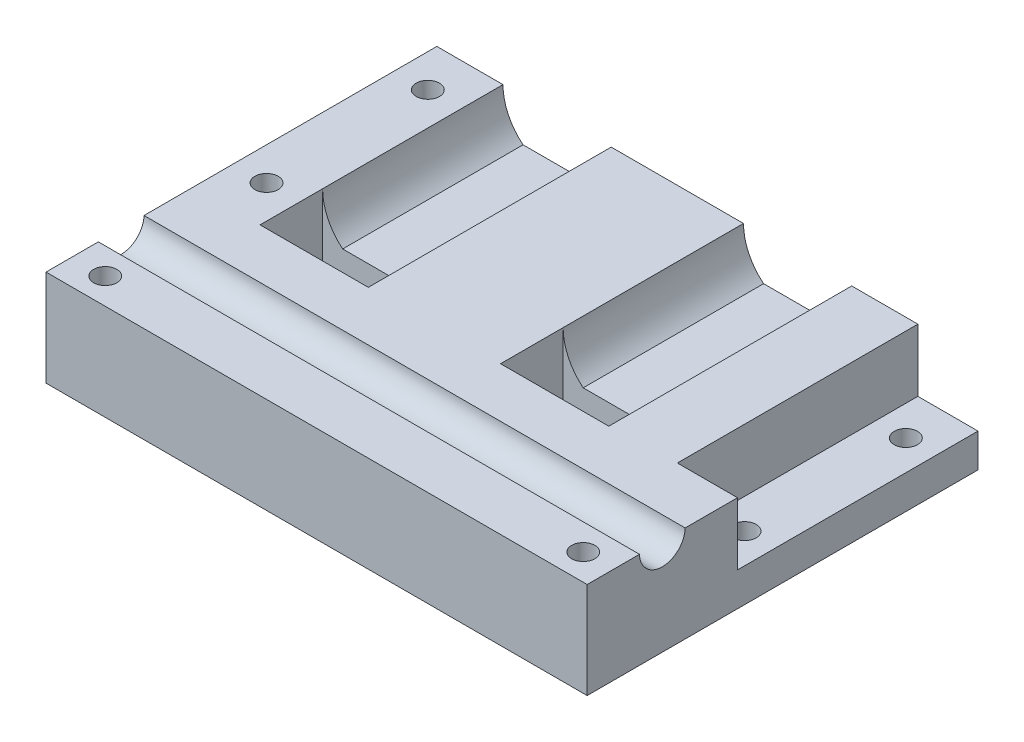
from build123d import *

# Parameters (mm, degrees)
BOSS_EXTRUDE1_DEPTH  = 38.1
SKETCH7_W            = 101.6
SKETCH7_H            = 20.32
BOSS_EXTRUDE2_DEPTH  = 44.45
BOSS_EXTRUDE8_DEPTH  = 12.7
SKETCH8_W            = 22.86
SKETCH8_H            = 13.208
CUT_EXTRUDE1_DEPTH   = 20.32
SKETCH9_R            = 4.826
CUT_EXTRUDE2_DEPTH   = 114.3
LPATTERN1_COUNT      = 3
LPATTERN1_PITCH      = 34.067332164
LPATTERN1_COUNT_DIR2 = 2
LPATTERN1_PITCH_DIR2 = 100.965


with BuildPart() as part:
    # Sketch1 → Boss-Extrude1 (new body)
    with BuildSketch(Plane.XY):
        with BuildLine():
            Line((-50.8, 0), (50.8, 0))
            Line((50.8, 0), (50.8, 20.32))
            Line((50.8, 20.32), (36.83, 20.32))
            ThreePointArc((36.83, 20.32), (35.714076836, 15.394076836), (32.584204897, 11.43))
            Line((32.584204897, 11.43), (18.215795103, 11.43))
            ThreePointArc((18.215795103, 11.43), (15.085923164, 15.394076836), (13.97, 20.32))
            Line((13.97, 20.32), (-13.97, 20.32))
            ThreePointArc((-13.97, 20.32), (-15.085923164, 15.394076836), (-18.215795103, 11.43))
            Line((-18.215795103, 11.43), (-32.584204897, 11.43))
            ThreePointArc((-32.584204897, 11.43), (-35.714076836, 15.394076836), (-36.83, 20.32))
            Line((-36.83, 20.32), (-50.8, 20.32))
            Line((-50.8, 20.32), (-50.8, 0))
        make_face()
    extrude(amount=BOSS_EXTRUDE1_DEPTH)

    # Sketch7 → Boss-Extrude2 (add)
    with BuildSketch(Plane.XY.offset(38.1)):
        with Locations((0, 10.16)):
            Rectangle(SKETCH7_W, SKETCH7_H)
    extrude(amount=BOSS_EXTRUDE2_DEPTH)

    # Sketch20 → Boss-Extrude8 (add)
    with BuildSketch(Plane(origin=(50.8, 0, 0), x_dir=(0, 0, -1), z_dir=(1, 0, 0))):
        Polygon((-50.8, 0), (0, 0), (0, 7.112), (-50.8, 7.112), (-50.8, 20.32), (-82.55, 20.32), (-82.55, 3.874334441), (-82.55, 0), align=None)
    extrude(amount=BOSS_EXTRUDE8_DEPTH)

    # Sketch8 → Cut-Extrude1 (cut)
    with BuildSketch(Plane(origin=(0, 20.32, 0), x_dir=(1, 0, 0), z_dir=(0, 1, 0))):
        with Locations((-25.4, -44.704)):
            Rectangle(SKETCH8_W, SKETCH8_H)
        with Locations((25.4, -44.704)):
            Rectangle(SKETCH8_W, SKETCH8_H)
    extrude(amount=-CUT_EXTRUDE1_DEPTH, mode=Mode.SUBTRACT)

    # Sketch5 → #10 (0.1935) Diameter Hole1 (revolve, cut)
    with BuildSketch(Plane(origin=(-43.815, 20.32, 8.89), x_dir=(0, 0, 1), z_dir=(1, 0, 0))):
        Polygon((0, 0), (0, 25.4), (2.45745, 23.923415072), (2.45745, 0), align=None)
    f_10_0_1935_diameter_hole1 = revolve(axis=Axis((-43.815, 26.67, 8.89), (0, -1, 0)), mode=Mode.SUBTRACT)

    # Sketch9 → Cut-Extrude2 (cut)
    with BuildSketch(Plane.ZY.offset(50.8)):
        with Locations((66.675, 20.447)):
            Circle(SKETCH9_R)
    extrude(amount=-CUT_EXTRUDE2_DEPTH, mode=Mode.SUBTRACT)

    # LPattern1: 10 _0.1935_ Diameter Hole1 3 × 2
    with Locations(*[(j * LPATTERN1_PITCH_DIR2, 0, i * LPATTERN1_PITCH) for i in range(LPATTERN1_COUNT) for j in range(LPATTERN1_COUNT_DIR2) if (i, j) != (0, 0)]):
        add(f_10_0_1935_diameter_hole1, mode=Mode.SUBTRACT)


solid = part.part
